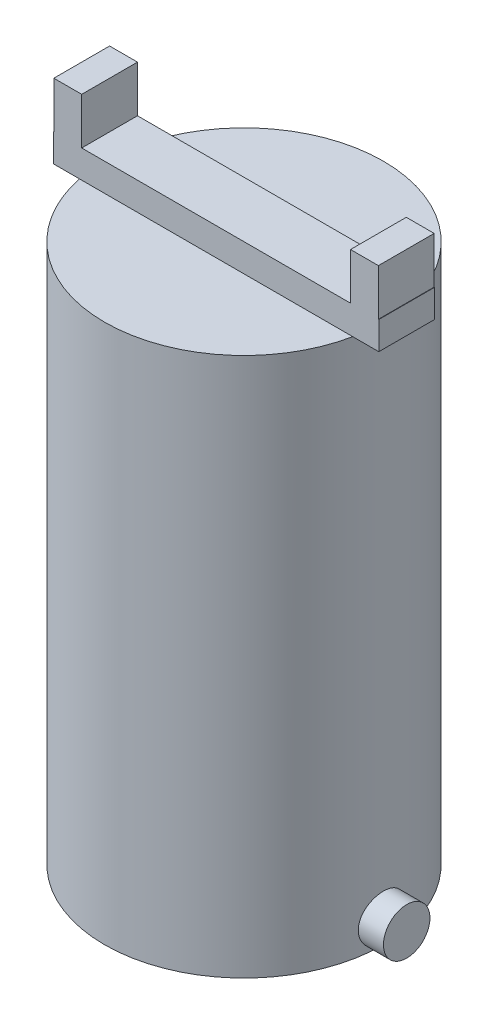
from build123d import *

# Parameters (mm, degrees)
SKETCH1_R           = 15
BOSS_EXTRUDE1_DEPTH = 58
SKETCH4_W           = 35
SKETCH4_H           = 6
BOSS_EXTRUDE3_DEPTH = 3
SKETCH5_W           = 3
SKETCH5_H           = 6
BOSS_EXTRUDE4_DEPTH = 5
SKETCH6_R           = 2.5
BOSS_EXTRUDE5_DEPTH = 17.5


with BuildPart() as part:
    # Sketch1 → Boss-Extrude1 (new body)
    with BuildSketch(Plane(origin=(0, 0, 0), x_dir=(1, 0, 0), z_dir=(0, 1, 0))):
        with Locations(Location((0, 0, 0), (0, 0, 90))):
            Circle(SKETCH1_R)
    extrude(amount=BOSS_EXTRUDE1_DEPTH)

    # Sketch4 → Boss-Extrude3 (add)
    with BuildSketch(Plane(origin=(0, 58, 0), x_dir=(1, 0, 0), z_dir=(0, 1, 0))):
        Rectangle(SKETCH4_W, SKETCH4_H)
    extrude(amount=BOSS_EXTRUDE3_DEPTH)

    # Sketch5 → Boss-Extrude4 (add)
    with BuildSketch(Plane(origin=(0, 61, 0), x_dir=(1, 0, 0), z_dir=(0, 1, 0))):
        with Locations((-15.95745503, 0)):
            Rectangle(SKETCH5_W, SKETCH5_H)
    boss_extrude4 = extrude(amount=BOSS_EXTRUDE4_DEPTH)

    # Mirror2: Boss-Extrude4 across plane
    add(boss_extrude4.mirror(Plane(origin=(0, 0, 0), x_dir=(0, 0, 1), z_dir=(1, 0, 0))))

    # Sketch6 → Boss-Extrude5 (add)
    with BuildSketch(Plane(origin=(0, 0, 0), x_dir=(0, 0, -1), z_dir=(1, 0, 0))):
        with Locations(Location((0, 2.5, 0), (0, 0, 270))):
            Circle(SKETCH6_R)
    boss_extrude5 = extrude(amount=BOSS_EXTRUDE5_DEPTH)

    # Mirror3: Boss-Extrude5 across plane
    add(boss_extrude5.mirror(Plane(origin=(0, 0, 0), x_dir=(0, 0, 1), z_dir=(1, 0, 0))))


solid = part.part
